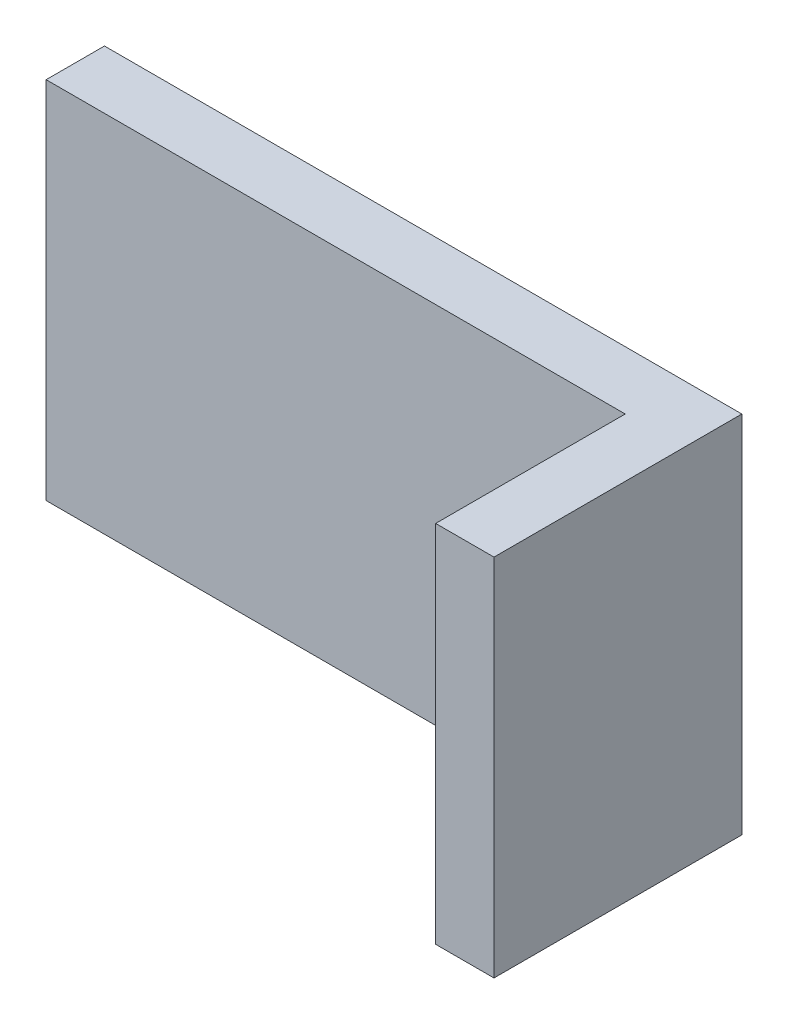
from build123d import *

# Parameters (mm, degrees)
BOSS_EXTRUDE1_DEPTH = 25


with BuildPart() as part:
    # Sketch1 → Boss-Extrude1 (new body, symmetric)
    with BuildSketch(Plane(origin=(0, 0, 0), x_dir=(1, 0, 0), z_dir=(0, 1, 0))):
        Polygon((0, 0), (-79.428571429, 0), (-79.428571429, 8), (8, 8), (8, -26), (0, -26), align=None)
    extrude(amount=BOSS_EXTRUDE1_DEPTH, both=True)


solid = part.part
